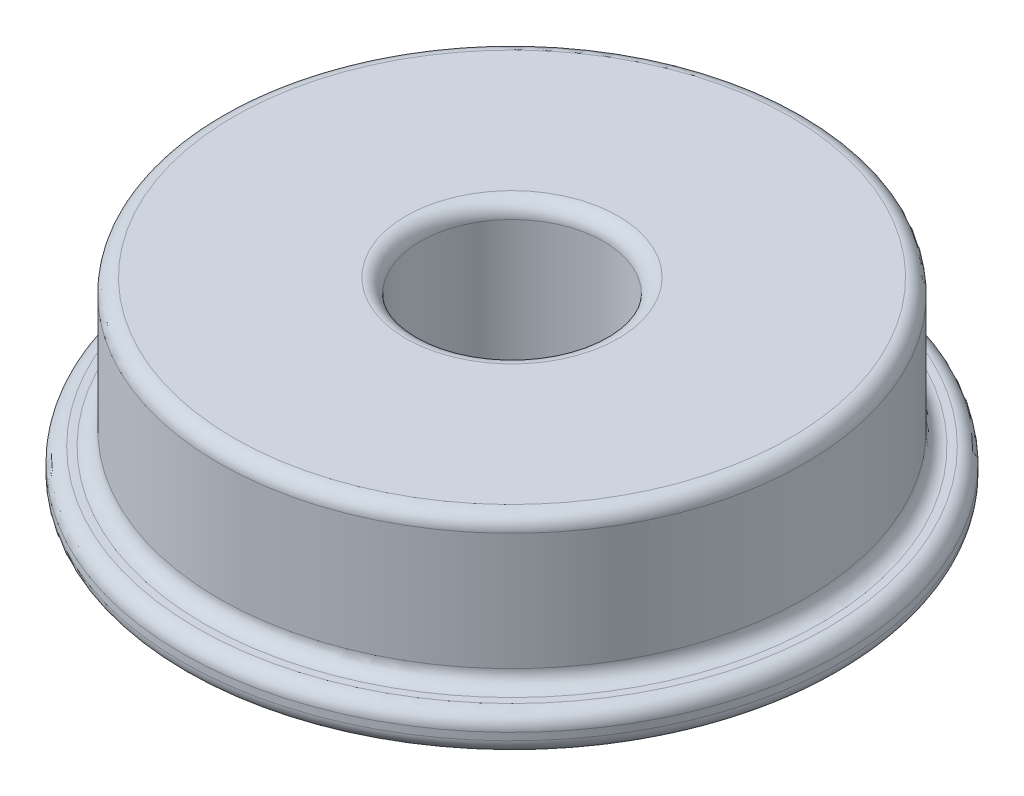
from build123d import *

# Parameters (mm, degrees)
SKETCH1_R           = 9
BOSS_EXTRUDE1_DEPTH = 1
SKETCH2_R           = 8
BOSS_EXTRUDE2_DEPTH = 4
SKETCH3_R           = 2.5
CUT_EXTRUDE1_DEPTH  = 6
FILLET1_R           = 0.4


with BuildPart() as part:
    # Sketch1 → Boss-Extrude1 (new body)
    with BuildSketch(Plane(origin=(0, 0, 0), x_dir=(1, 0, 0), z_dir=(0, 1, 0))):
        Circle(SKETCH1_R)
    extrude(amount=BOSS_EXTRUDE1_DEPTH)

    # Sketch2 → Boss-Extrude2 (add)
    with BuildSketch(Plane(origin=(0, 1, 0), x_dir=(1, 0, 0), z_dir=(0, 1, 0))):
        Circle(SKETCH2_R)
    extrude(amount=BOSS_EXTRUDE2_DEPTH)

    # Sketch3 → Cut-Extrude1 (cut, through all)
    with BuildSketch(Plane(origin=(0, 5, 0), x_dir=(1, 0, 0), z_dir=(0, 1, 0))):
        Circle(SKETCH3_R)
    extrude(amount=-CUT_EXTRUDE1_DEPTH, mode=Mode.SUBTRACT)

    # Fillet1
    fillet1_edges = [part.edges().sort_by_distance(p)[0] for p in [
        (-2.5, 0, 0),
        (-2.5, 5, 0),
        (-9, 0, 0),
        (-9, 1, 0),
        (-8, 1, 0),
        (-8, 5, 0),
    ]]
    fillet(fillet1_edges, radius=FILLET1_R)


solid = part.part
